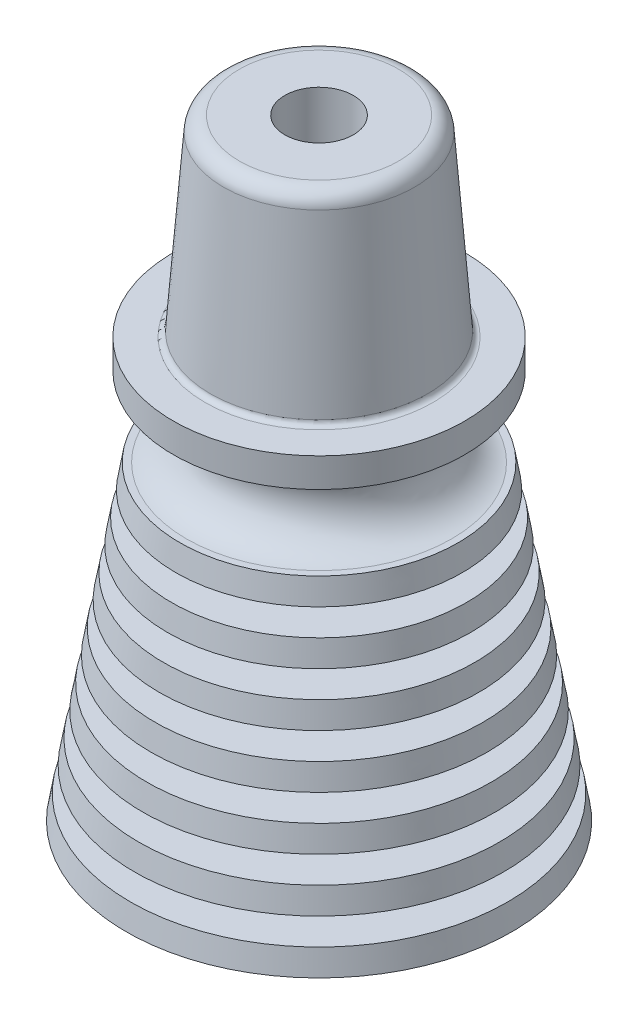
from build123d import *

# Parameters (mm, degrees)
SKETCH5_R          = 1.6383
CUT_EXTRUDE1_DEPTH = 30.2608
FILLET1_R          = 0.762
FILLET2_R          = 0.254


with BuildPart() as part:
    # Sketch1 → Revolve1 (revolve)
    with BuildSketch(Plane.XY, mode=Mode.PRIVATE) as revolve1_sk:
        Polygon((4.571997254, 14.859), (6.235697254, 0), (4.191, 0), (2.5273, 14.859), align=None)
    revolve(revolve1_sk.sketch.rotate(Axis((0, 0, 0), (0, 1, 0)), 90), axis=Axis((0, 0, 0), (0, 1, 0)))  # turned: the seam where the file's is

    # Sketch2 → Revolve2 (revolve)
    with BuildSketch(Plane.XY, mode=Mode.PRIVATE) as revolve2_sk:
        Polygon((6.235697254, 0), (9.2329, 0), (9.035561538, 1.143), (6.107720331, 1.143), align=None)
        Polygon((4.571997254, 14.859), (4.699974177, 13.716), (6.864838462, 13.716), (6.6675, 14.859), align=None)
        Polygon((5.979743408, 2.286), (8.838223077, 2.286), (8.640884615, 3.429), (5.851766485, 3.429), align=None)
        Polygon((5.723789562, 4.572), (8.443546154, 4.572), (8.246207692, 5.715), (5.595812639, 5.715), align=None)
        Polygon((5.467835716, 6.858), (8.048869231, 6.858), (7.851530769, 8.001), (5.339858793, 8.001), align=None)
        Polygon((5.21188187, 9.144), (7.654192308, 9.144), (7.456853846, 10.287), (5.083904947, 10.287), align=None)
        Polygon((4.955928023, 11.43), (7.259515385, 11.43), (7.062176923, 12.573), (4.8279511, 12.573), align=None)
    revolve(revolve2_sk.sketch.rotate(Axis((0, 0, 0), (0, 1, 0)), 90), axis=Axis((0, 0, 0), (0, 1, 0)))  # turned: the seam where the file's is

    # Sketch3 → Revolve3 (revolve)
    with BuildSketch(Plane.XY, mode=Mode.PRIVATE) as revolve3_sk:
        with BuildLine():
            Line((6.35, 14.859), (0, 14.859))
            Line((0, 14.859), (0, 20.066))
            Line((0, 20.066), (6.985, 20.066))
            Line((6.985, 20.066), (6.985, 18.669))
            Line((6.985, 18.669), (6.35, 18.669))
            ThreePointArc((6.35, 18.669), (4.6863, 16.764), (6.35, 14.859))
        make_face()
    revolve(revolve3_sk.sketch.rotate(Axis((0, 0, 0), (0, 1, 0)), 90), axis=Axis((0, 0, 0), (0, 1, 0)))  # turned: the seam where the file's is

    # Sketch4 → Revolve4 (revolve)
    with BuildSketch(Plane.XY, mode=Mode.PRIVATE) as revolve4_sk:
        Polygon((5.2197, 20.066), (0, 20.066), (0, 29.2608), (4.5212, 29.2608), align=None)
    revolve(revolve4_sk.sketch.rotate(Axis((0, 0, 0), (0, 1, 0)), 90), axis=Axis((0, 0, 0), (0, 1, 0)))  # turned: the seam where the file's is

    # Sketch5 → Cut-Extrude1 (cut, through all)
    with BuildSketch(Plane(origin=(0, 29.2608, 0), x_dir=(1, 0, 0), z_dir=(0, 1, 0))):
        with Locations(Location((0, 0, 0), (0, 0, 270))):  # turned: the seam where the file's is
            Circle(SKETCH5_R)
    extrude(amount=-CUT_EXTRUDE1_DEPTH, mode=Mode.SUBTRACT)

    # Fillet1
    fillet1_edges = [part.edges().sort_by_distance(p)[0] for p in [
        (0, 29.2608, 4.5212),
    ]]
    fillet(fillet1_edges, radius=FILLET1_R)

    # Fillet2
    fillet2_edges = [part.edges().sort_by_distance(p)[0] for p in [
        (0, 20.066, 5.2197),
    ]]
    fillet(fillet2_edges, radius=FILLET2_R)


solid = part.part
